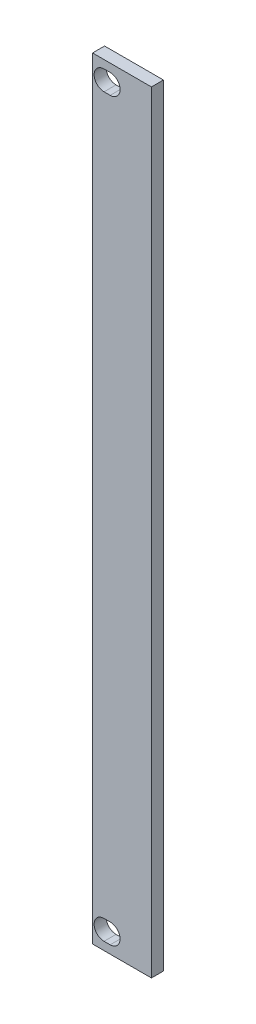
from build123d import *

# Parameters (mm, degrees)
SKETCH1_W           = 9.8
SKETCH1_H           = 128.5
BOSS_EXTRUDE1_DEPTH = 2


with BuildPart() as part:
    # Sketch1 → Boss-Extrude1 (new body)
    with BuildSketch(Plane.XY):
        Rectangle(SKETCH1_W, SKETCH1_H)
        with BuildLine():
            Line((-2.988, -59.6), (-1.972, -59.6))
            ThreePointArc((-1.972, -59.6), (-0.322, -61.25), (-1.972, -62.9))
            Line((-1.972, -62.9), (-2.988, -62.9))
            ThreePointArc((-2.988, -62.9), (-4.638, -61.25), (-2.988, -59.6))
        make_face(mode=Mode.SUBTRACT)
        with BuildLine():
            Line((-2.988, 62.9), (-1.972, 62.9))
            ThreePointArc((-1.972, 62.9), (-0.322, 61.25), (-1.972, 59.6))
            Line((-1.972, 59.6), (-2.988, 59.6))
            ThreePointArc((-2.988, 59.6), (-4.638, 61.25), (-2.988, 62.9))
        make_face(mode=Mode.SUBTRACT)
    extrude(amount=BOSS_EXTRUDE1_DEPTH)


solid = part.part
